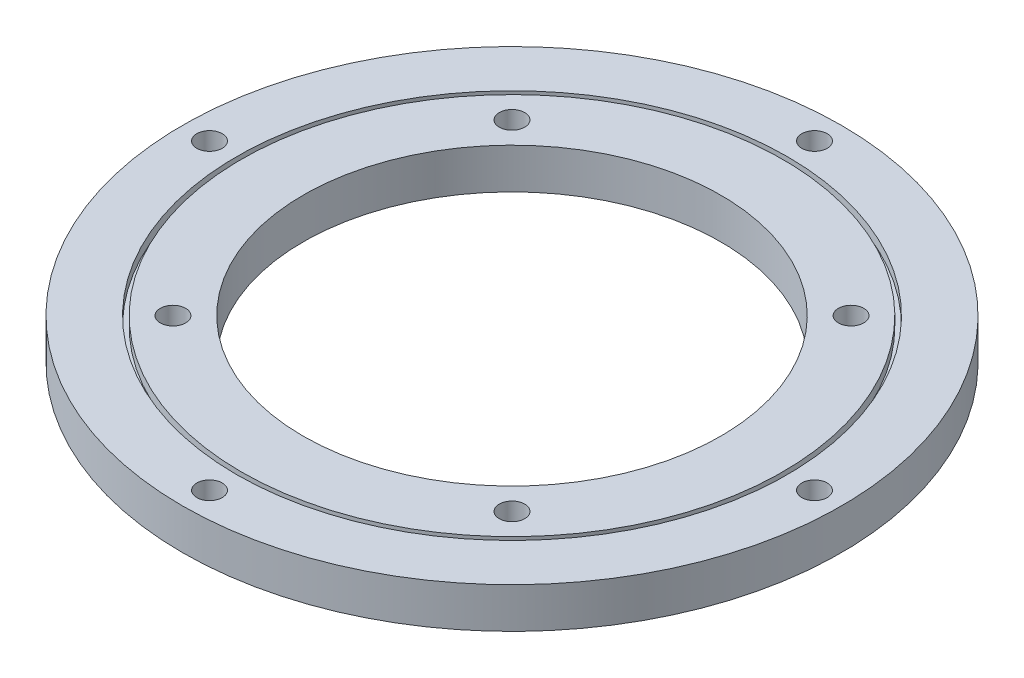
from build123d import *

# Parameters (mm, degrees)
SKETCH1_R           = 70
SKETCH1_R_2         = 44.35
BOSS_EXTRUDE1_DEPTH = 8.6
SKETCH2_R           = 58.5
SKETCH2_R_2         = 57.5
CUT_EXTRUDE1_DEPTH  = 2
SKETCH3_R           = 2.7
CUT_EXTRUDE2_DEPTH  = 9.6
SKETCH4_R           = 2.7
CUT_EXTRUDE3_DEPTH  = 9.6


with BuildPart() as part:
    # Sketch1 → Boss-Extrude1 (new body)
    with BuildSketch(Plane(origin=(0, 0, 0), x_dir=(1, 0, 0), z_dir=(0, 1, 0))):
        Circle(SKETCH1_R)
        Circle(SKETCH1_R_2, mode=Mode.SUBTRACT)
    extrude(amount=BOSS_EXTRUDE1_DEPTH)

    # Sketch2 → Cut-Extrude1 (cut)
    with BuildSketch(Plane(origin=(0, 8.6, 0), x_dir=(1, 0, 0), z_dir=(0, 1, 0))):
        Circle(SKETCH2_R)
        Circle(SKETCH2_R_2, mode=Mode.SUBTRACT)
    cut_extrude1 = extrude(amount=-CUT_EXTRUDE1_DEPTH, mode=Mode.SUBTRACT)

    # Mirror1: Cut-Extrude1 across plane
    add(cut_extrude1.mirror(Plane.ZX.offset(4.3)), mode=Mode.SUBTRACT)

    # Sketch3 → Cut-Extrude2 (cut, through all)
    with BuildSketch(Plane(origin=(0, 8.6, 0), x_dir=(1, 0, 0), z_dir=(0, 1, 0))):
        with Locations((0, 64.25)):
            Circle(SKETCH3_R)
        with Locations((64.25, 0)):
            Circle(SKETCH3_R)
        with Locations((0, -64.25)):
            Circle(SKETCH3_R)
        with Locations((-64.25, 0)):
            Circle(SKETCH3_R)
    extrude(amount=-CUT_EXTRUDE2_DEPTH, mode=Mode.SUBTRACT)

    # Sketch4 → Cut-Extrude3 (cut, through all)
    with BuildSketch(Plane(origin=(0, 8.6, 0), x_dir=(1, 0, 0), z_dir=(0, 1, 0))):
        with Locations((-36.009412832, 36.009412832)):
            Circle(SKETCH4_R)
        with Locations((36.009412832, 36.009412832)):
            Circle(SKETCH4_R)
        with Locations((36.009412832, -36.009412832)):
            Circle(SKETCH4_R)
        with Locations((-36.009412832, -36.009412832)):
            Circle(SKETCH4_R)
    extrude(amount=-CUT_EXTRUDE3_DEPTH, mode=Mode.SUBTRACT)


solid = part.part
